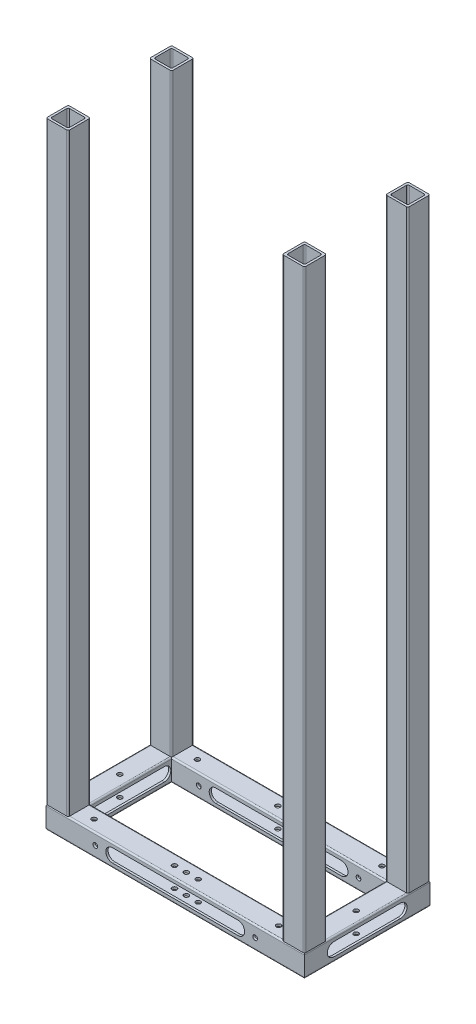
from build123d import *

# Parameters (mm, degrees)
MEMBER_1_DEPTH      = 171.606601718
MEMBER_1_DEPTH_BACK = 11.606601718
MEMBER_1_2_DEPTH    = 93.213203436
MEMBER_1_3_DEPTH    = 183.213203436
MEMBER_1_4_DEPTH    = 93.213203436
MEMBER_2_DEPTH      = 410
MEMBER_2_2_DEPTH    = 410
MEMBER_2_3_DEPTH    = 410
MEMBER_2_4_DEPTH    = 410
CUT_EXTRUDE_START   = -15
SKETCH_13_R         = 1.6
CUT_EXTRUDE_1_DEPTH = 15
CUT_EXTRUDE_START_2 = -85
SKETCH_15_R         = 1.6
CUT_EXTRUDE_2_DEPTH = 85
SKETCH_16_R         = 1.6
CUT_EXTRUDE_3_DEPTH = 15
SKETCH_17_R         = 1.6
CUT_EXTRUDE_4_DEPTH = 15
SKETCH_18_R         = 1.6
CUT_EXTRUDE_5_DEPTH = 15
CUT_EXTRUDE_7_DEPTH = 85
CUT_EXTRUDE_8_DEPTH = 176


with BuildPart() as part:
    # 草图11 → Member 1 (new, two sides)
    with BuildSketch(Plane(origin=(-80, 0, 35), x_dir=(0, 0, -1), z_dir=(1, 0, 0))) as member_1_sk:
        with BuildLine():
            Line((-6.5, 7.5), (6.5, 7.5))
            ThreePointArc((6.5, 7.5), (7.207106781, 7.207106781), (7.5, 6.5))
            Line((7.5, 6.5), (7.5, -6.5))
            ThreePointArc((7.5, -6.5), (7.207106781, -7.207106781), (6.5, -7.5))
            Line((6.5, -7.5), (-6.5, -7.5))
            ThreePointArc((-6.5, -7.5), (-7.207106781, -7.207106781), (-7.5, -6.5))
            Line((-7.5, -6.5), (-7.5, 6.5))
            ThreePointArc((-7.5, 6.5), (-7.207106781, 7.207106781), (-6.5, 7.5))
        make_face()
        with BuildLine():
            Line((-5, 6), (5, 6))
            ThreePointArc((5, 6), (5.707106781, 5.707106781), (6, 5))
            Line((6, 5), (6, -5))
            ThreePointArc((6, -5), (5.707106781, -5.707106781), (5, -6))
            Line((5, -6), (-5, -6))
            ThreePointArc((-5, -6), (-5.707106781, -5.707106781), (-6, -5))
            Line((-6, -5), (-6, 5))
            ThreePointArc((-6, 5), (-5.707106781, 5.707106781), (-5, 6))
        make_face(mode=Mode.SUBTRACT)
    extrude(amount=MEMBER_1_DEPTH)
    extrude(member_1_sk.sketch, amount=-MEMBER_1_DEPTH_BACK)

    # Member 1 mitre 1
    split(bisect_by=Plane(origin=(-80, 0, 35), x_dir=(0, 1, 0), z_dir=(0.707106781, 0, 0.707106781)), keep=Keep.TOP)

    # Member 1 mitre 2
    split(bisect_by=Plane(origin=(80, 0, 35), x_dir=(0, -1, 0), z_dir=(-0.707106781, 0, 0.707106781)), keep=Keep.TOP)


with BuildPart() as body_2:
    # 草图11 on segment 2 (carried to segment 2) → Member 1 2 (new body)
    with BuildSketch(Plane(origin=(80, 0, 46.606601718), x_dir=(-1, 0, 0), z_dir=(0, 0, -1))):
        with BuildLine():
            Line((-6.5, 7.5), (6.5, 7.5))
            ThreePointArc((6.5, 7.5), (7.207106781, 7.207106781), (7.5, 6.5))
            Line((7.5, 6.5), (7.5, -6.5))
            ThreePointArc((7.5, -6.5), (7.207106781, -7.207106781), (6.5, -7.5))
            Line((6.5, -7.5), (-6.5, -7.5))
            ThreePointArc((-6.5, -7.5), (-7.207106781, -7.207106781), (-7.5, -6.5))
            Line((-7.5, -6.5), (-7.5, 6.5))
            ThreePointArc((-7.5, 6.5), (-7.207106781, 7.207106781), (-6.5, 7.5))
        make_face()
        with BuildLine():
            Line((-5, 6), (5, 6))
            ThreePointArc((5, 6), (5.707106781, 5.707106781), (6, 5))
            Line((6, 5), (6, -5))
            ThreePointArc((6, -5), (5.707106781, -5.707106781), (5, -6))
            Line((5, -6), (-5, -6))
            ThreePointArc((-5, -6), (-5.707106781, -5.707106781), (-6, -5))
            Line((-6, -5), (-6, 5))
            ThreePointArc((-6, 5), (-5.707106781, 5.707106781), (-5, 6))
        make_face(mode=Mode.SUBTRACT)
    extrude(amount=MEMBER_1_2_DEPTH)

    # Member 1 2 mitre 1
    split(bisect_by=Plane(origin=(80, 0, -35), x_dir=(0, 1, 0), z_dir=(0.707106781, 0, 0.707106781)), keep=Keep.TOP)

    # Member 1 2 mitre 2
    split(bisect_by=Plane(origin=(80, 0, 35), x_dir=(0, 1, 0), z_dir=(0.707106781, 0, -0.707106781)), keep=Keep.TOP)


with BuildPart() as body_3:
    # 草图11 on segment 3 (carried to segment 3) → Member 1 3 (new body)
    with BuildSketch(Plane(origin=(91.606601718, 0, -35), x_dir=(0, 0, 1), z_dir=(-1, 0, 0))):
        with BuildLine():
            Line((-6.5, 7.5), (6.5, 7.5))
            ThreePointArc((6.5, 7.5), (7.207106781, 7.207106781), (7.5, 6.5))
            Line((7.5, 6.5), (7.5, -6.5))
            ThreePointArc((7.5, -6.5), (7.207106781, -7.207106781), (6.5, -7.5))
            Line((6.5, -7.5), (-6.5, -7.5))
            ThreePointArc((-6.5, -7.5), (-7.207106781, -7.207106781), (-7.5, -6.5))
            Line((-7.5, -6.5), (-7.5, 6.5))
            ThreePointArc((-7.5, 6.5), (-7.207106781, 7.207106781), (-6.5, 7.5))
        make_face()
        with BuildLine():
            Line((-5, 6), (5, 6))
            ThreePointArc((5, 6), (5.707106781, 5.707106781), (6, 5))
            Line((6, 5), (6, -5))
            ThreePointArc((6, -5), (5.707106781, -5.707106781), (5, -6))
            Line((5, -6), (-5, -6))
            ThreePointArc((-5, -6), (-5.707106781, -5.707106781), (-6, -5))
            Line((-6, -5), (-6, 5))
            ThreePointArc((-6, 5), (-5.707106781, 5.707106781), (-5, 6))
        make_face(mode=Mode.SUBTRACT)
    extrude(amount=MEMBER_1_3_DEPTH)

    # Member 1 3 mitre 1
    split(bisect_by=Plane(origin=(-80, 0, -35), x_dir=(0, 1, 0), z_dir=(0.707106781, 0, -0.707106781)), keep=Keep.TOP)

    # Member 1 3 mitre 2
    split(bisect_by=Plane(origin=(80, 0, -35), x_dir=(0, -1, 0), z_dir=(-0.707106781, 0, -0.707106781)), keep=Keep.TOP)


with BuildPart() as body_4:
    # 草图11 on segment 4 (carried to segment 4) → Member 1 4 (new body)
    with BuildSketch(Plane(origin=(-80, 0, -46.606601718), x_dir=(1, 0, 0), z_dir=(0, 0, 1))):
        with BuildLine():
            Line((-6.5, 7.5), (6.5, 7.5))
            ThreePointArc((6.5, 7.5), (7.207106781, 7.207106781), (7.5, 6.5))
            Line((7.5, 6.5), (7.5, -6.5))
            ThreePointArc((7.5, -6.5), (7.207106781, -7.207106781), (6.5, -7.5))
            Line((6.5, -7.5), (-6.5, -7.5))
            ThreePointArc((-6.5, -7.5), (-7.207106781, -7.207106781), (-7.5, -6.5))
            Line((-7.5, -6.5), (-7.5, 6.5))
            ThreePointArc((-7.5, 6.5), (-7.207106781, 7.207106781), (-6.5, 7.5))
        make_face()
        with BuildLine():
            Line((-5, 6), (5, 6))
            ThreePointArc((5, 6), (5.707106781, 5.707106781), (6, 5))
            Line((6, 5), (6, -5))
            ThreePointArc((6, -5), (5.707106781, -5.707106781), (5, -6))
            Line((5, -6), (-5, -6))
            ThreePointArc((-5, -6), (-5.707106781, -5.707106781), (-6, -5))
            Line((-6, -5), (-6, 5))
            ThreePointArc((-6, 5), (-5.707106781, 5.707106781), (-5, 6))
        make_face(mode=Mode.SUBTRACT)
    extrude(amount=MEMBER_1_4_DEPTH)

    # Member 1 4 mitre 1
    split(bisect_by=Plane(origin=(-80, 0, -35), x_dir=(0, -1, 0), z_dir=(-0.707106781, 0, 0.707106781)), keep=Keep.TOP)

    # Member 1 4 mitre 2
    split(bisect_by=Plane(origin=(-80, 0, 35), x_dir=(0, -1, 0), z_dir=(-0.707106781, 0, -0.707106781)), keep=Keep.TOP)


with BuildPart() as body_5:
    # 草图12 → Member 2 (new body)
    with BuildSketch(Plane(origin=(-80, 0, 35), x_dir=(1, 0, 0), z_dir=(0, 1, 0))):
        with BuildLine():
            Line((-6.5, 7.5), (6.5, 7.5))
            ThreePointArc((6.5, 7.5), (7.207106781, 7.207106781), (7.5, 6.5))
            Line((7.5, 6.5), (7.5, -6.5))
            ThreePointArc((7.5, -6.5), (7.207106781, -7.207106781), (6.5, -7.5))
            Line((6.5, -7.5), (-6.5, -7.5))
            ThreePointArc((-6.5, -7.5), (-7.207106781, -7.207106781), (-7.5, -6.5))
            Line((-7.5, -6.5), (-7.5, 6.5))
            ThreePointArc((-7.5, 6.5), (-7.207106781, 7.207106781), (-6.5, 7.5))
        make_face()
        with BuildLine():
            Line((-5, 6), (5, 6))
            ThreePointArc((5, 6), (5.707106781, 5.707106781), (6, 5))
            Line((6, 5), (6, -5))
            ThreePointArc((6, -5), (5.707106781, -5.707106781), (5, -6))
            Line((5, -6), (-5, -6))
            ThreePointArc((-5, -6), (-5.707106781, -5.707106781), (-6, -5))
            Line((-6, -5), (-6, 5))
            ThreePointArc((-6, 5), (-5.707106781, 5.707106781), (-5, 6))
        make_face(mode=Mode.SUBTRACT)
    extrude(amount=MEMBER_2_DEPTH)

    # Weld Trim 1 5
    split(bisect_by=Plane(origin=(0, 7.5, 35.176724987), x_dir=(-1, 0, 0), z_dir=(0, 1, 0)), keep=Keep.TOP)


with BuildPart() as body_6:
    # 草图12 on segment 2 (carried to segment 2) → Member 2 2 (new body)
    with BuildSketch(Plane(origin=(-80, 0, -35), x_dir=(1, 0, 0), z_dir=(0, 1, 0))):
        with BuildLine():
            Line((-6.5, 7.5), (6.5, 7.5))
            ThreePointArc((6.5, 7.5), (7.207106781, 7.207106781), (7.5, 6.5))
            Line((7.5, 6.5), (7.5, -6.5))
            ThreePointArc((7.5, -6.5), (7.207106781, -7.207106781), (6.5, -7.5))
            Line((6.5, -7.5), (-6.5, -7.5))
            ThreePointArc((-6.5, -7.5), (-7.207106781, -7.207106781), (-7.5, -6.5))
            Line((-7.5, -6.5), (-7.5, 6.5))
            ThreePointArc((-7.5, 6.5), (-7.207106781, 7.207106781), (-6.5, 7.5))
        make_face()
        with BuildLine():
            Line((-5, 6), (5, 6))
            ThreePointArc((5, 6), (5.707106781, 5.707106781), (6, 5))
            Line((6, 5), (6, -5))
            ThreePointArc((6, -5), (5.707106781, -5.707106781), (5, -6))
            Line((5, -6), (-5, -6))
            ThreePointArc((-5, -6), (-5.707106781, -5.707106781), (-6, -5))
            Line((-6, -5), (-6, 5))
            ThreePointArc((-6, 5), (-5.707106781, 5.707106781), (-5, 6))
        make_face(mode=Mode.SUBTRACT)
    extrude(amount=MEMBER_2_2_DEPTH)

    # Weld Trim 1 5
    split(bisect_by=Plane(origin=(0, 7.5, 35.176724987), x_dir=(-1, 0, 0), z_dir=(0, 1, 0)), keep=Keep.TOP)


with BuildPart() as body_7:
    # 草图12 on segment 3 (carried to segment 3) → Member 2 3 (new body)
    with BuildSketch(Plane(origin=(80, 0, -35), x_dir=(1, 0, 0), z_dir=(0, 1, 0))):
        with BuildLine():
            Line((-6.5, 7.5), (6.5, 7.5))
            ThreePointArc((6.5, 7.5), (7.207106781, 7.207106781), (7.5, 6.5))
            Line((7.5, 6.5), (7.5, -6.5))
            ThreePointArc((7.5, -6.5), (7.207106781, -7.207106781), (6.5, -7.5))
            Line((6.5, -7.5), (-6.5, -7.5))
            ThreePointArc((-6.5, -7.5), (-7.207106781, -7.207106781), (-7.5, -6.5))
            Line((-7.5, -6.5), (-7.5, 6.5))
            ThreePointArc((-7.5, 6.5), (-7.207106781, 7.207106781), (-6.5, 7.5))
        make_face()
        with BuildLine():
            Line((-5, 6), (5, 6))
            ThreePointArc((5, 6), (5.707106781, 5.707106781), (6, 5))
            Line((6, 5), (6, -5))
            ThreePointArc((6, -5), (5.707106781, -5.707106781), (5, -6))
            Line((5, -6), (-5, -6))
            ThreePointArc((-5, -6), (-5.707106781, -5.707106781), (-6, -5))
            Line((-6, -5), (-6, 5))
            ThreePointArc((-6, 5), (-5.707106781, 5.707106781), (-5, 6))
        make_face(mode=Mode.SUBTRACT)
    extrude(amount=MEMBER_2_3_DEPTH)

    # Weld Trim 1 5
    split(bisect_by=Plane(origin=(0, 7.5, 35.176724987), x_dir=(-1, 0, 0), z_dir=(0, 1, 0)), keep=Keep.TOP)


with BuildPart() as body_8:
    # 草图12 on segment 4 (carried to segment 4) → Member 2 4 (new body)
    with BuildSketch(Plane(origin=(80, 0, 35), x_dir=(1, 0, 0), z_dir=(0, 1, 0))):
        with BuildLine():
            Line((-6.5, 7.5), (6.5, 7.5))
            ThreePointArc((6.5, 7.5), (7.207106781, 7.207106781), (7.5, 6.5))
            Line((7.5, 6.5), (7.5, -6.5))
            ThreePointArc((7.5, -6.5), (7.207106781, -7.207106781), (6.5, -7.5))
            Line((6.5, -7.5), (-6.5, -7.5))
            ThreePointArc((-6.5, -7.5), (-7.207106781, -7.207106781), (-7.5, -6.5))
            Line((-7.5, -6.5), (-7.5, 6.5))
            ThreePointArc((-7.5, 6.5), (-7.207106781, 7.207106781), (-6.5, 7.5))
        make_face()
        with BuildLine():
            Line((-5, 6), (5, 6))
            ThreePointArc((5, 6), (5.707106781, 5.707106781), (6, 5))
            Line((6, 5), (6, -5))
            ThreePointArc((6, -5), (5.707106781, -5.707106781), (5, -6))
            Line((5, -6), (-5, -6))
            ThreePointArc((-5, -6), (-5.707106781, -5.707106781), (-6, -5))
            Line((-6, -5), (-6, 5))
            ThreePointArc((-6, 5), (-5.707106781, 5.707106781), (-5, 6))
        make_face(mode=Mode.SUBTRACT)
    extrude(amount=MEMBER_2_4_DEPTH)

    # Weld Trim 1 5
    split(bisect_by=Plane(origin=(0, 7.5, 35.176724987), x_dir=(-1, 0, 0), z_dir=(0, 1, 0)), keep=Keep.TOP)


with BuildPart() as cut_extrude_1_tool:
    # 草图13 → 切除-拉伸1 (new body)
    with BuildSketch(Plane(origin=(0, 7.5, 0), x_dir=(1, 0, 0), z_dir=(0, 1, 0)).offset(CUT_EXTRUDE_START)):
        with Locations(Location((0, -35, 0), (0, 0, 270))):
            Circle(SKETCH_13_R)
        with Locations(Location((0, 35, 0), (0, 0, 90))):
            Circle(SKETCH_13_R)
    extrude(amount=CUT_EXTRUDE_1_DEPTH)


with BuildPart() as part_1:
    add(part.part)

    # 切除-拉伸1: cut by cut_extrude_1_tool
    add(cut_extrude_1_tool.part, mode=Mode.SUBTRACT)


with BuildPart() as body_3_1:
    add(body_3.part)

    # 切除-拉伸1: cut by cut_extrude_1_tool
    add(cut_extrude_1_tool.part, mode=Mode.SUBTRACT)


with BuildPart() as cut_extrude_2_tool:
    # 草图15 → 切除-拉伸2 (new body)
    with BuildSketch(Plane(origin=(0, 0, -42.5), x_dir=(-1, 0, 0), z_dir=(0, 0, -1)).offset(CUT_EXTRUDE_START_2)):
        with Locations((-54.11, 0)):
            Circle(SKETCH_15_R)
        with Locations((54.11, 0)):
            Circle(SKETCH_15_R)
    extrude(amount=CUT_EXTRUDE_2_DEPTH)


with BuildPart() as part_2:
    add(part_1.part)

    # 切除-拉伸2: cut by cut_extrude_2_tool
    add(cut_extrude_2_tool.part, mode=Mode.SUBTRACT)


with BuildPart() as body_3_2:
    add(body_3_1.part)

    # 切除-拉伸2: cut by cut_extrude_2_tool
    add(cut_extrude_2_tool.part, mode=Mode.SUBTRACT)


with BuildPart() as cut_extrude_3_tool:
    # 草图16 → 切除-拉伸3 (new body)
    with BuildSketch(Plane(origin=(0, 7.5, 0), x_dir=(1, 0, 0), z_dir=(0, 1, 0)).offset(CUT_EXTRUDE_START)):
        with Locations(Location((80, 0, 0), (0, 0, 270))):
            Circle(SKETCH_16_R)
        with Locations(Location((-80, 0, 0), (0, 0, 270))):
            Circle(SKETCH_16_R)
    extrude(amount=CUT_EXTRUDE_3_DEPTH)


with BuildPart() as body_2_1:
    add(body_2.part)

    # 切除-拉伸3: cut by cut_extrude_3_tool
    add(cut_extrude_3_tool.part, mode=Mode.SUBTRACT)


with BuildPart() as body_4_1:
    add(body_4.part)

    # 切除-拉伸3: cut by cut_extrude_3_tool
    add(cut_extrude_3_tool.part, mode=Mode.SUBTRACT)


with BuildPart() as cut_extrude_4_tool:
    # 草图17 → 切除-拉伸4 (new body)
    with BuildSketch(Plane(origin=(0, 7.5, 0), x_dir=(1, 0, 0), z_dir=(0, 1, 0)).offset(CUT_EXTRUDE_START)):
        with Locations(Location((8, 35, 0), (0, 0, 180))):
            Circle(SKETCH_17_R)
        with Locations(Location((-8, 35, 0), (0, 0, 90))):
            Circle(SKETCH_17_R)
        with Locations(Location((-8, -35, 0), (0, 0, 180))):
            Circle(SKETCH_17_R)
        with Locations(Location((8, -35, 0), (0, 0, 90))):
            Circle(SKETCH_17_R)
    extrude(amount=CUT_EXTRUDE_4_DEPTH)


with BuildPart() as part_3:
    add(part_2.part)

    # 切除-拉伸4: cut by cut_extrude_4_tool
    add(cut_extrude_4_tool.part, mode=Mode.SUBTRACT)


with BuildPart() as body_3_3:
    add(body_3_2.part)

    # 切除-拉伸4: cut by cut_extrude_4_tool
    add(cut_extrude_4_tool.part, mode=Mode.SUBTRACT)


with BuildPart() as cut_extrude_5_tool:
    # 草图18 → 切除-拉伸5 (new body)
    with BuildSketch(Plane(origin=(0, 7.5, 0), x_dir=(1, 0, 0), z_dir=(0, 1, 0)).offset(CUT_EXTRUDE_START)):
        with Locations(Location((-62.5, -35, 0), (0, 0, 270))):
            Circle(SKETCH_18_R)
        with Locations(Location((62.5, -35, 0), (0, 0, 270))):
            Circle(SKETCH_18_R)
        with Locations(Location((62.5, 35, 0), (0, 0, 270))):
            Circle(SKETCH_18_R)
        with Locations(Location((-62.5, 35, 0), (0, 0, 270))):
            Circle(SKETCH_18_R)
    extrude(amount=CUT_EXTRUDE_5_DEPTH)


with BuildPart() as part_4:
    add(part_3.part)

    # 切除-拉伸5: cut by cut_extrude_5_tool
    add(cut_extrude_5_tool.part, mode=Mode.SUBTRACT)


with BuildPart() as body_3_4:
    add(body_3_3.part)

    # 切除-拉伸5: cut by cut_extrude_5_tool
    add(cut_extrude_5_tool.part, mode=Mode.SUBTRACT)


with BuildPart() as cut_extrude_7_tool:
    # 草图22 → 切除-拉伸7 (new body)
    with BuildSketch(Plane(origin=(0, 0, -42.5), x_dir=(-1, 0, 0), z_dir=(0, 0, -1))):
        with BuildLine():
            Line((-42.5, 4.5), (42.5, 4.5))
            ThreePointArc((42.5, 4.5), (47, 0), (42.5, -4.5))
            Line((42.5, -4.5), (-42.5, -4.5))
            ThreePointArc((-42.5, -4.5), (-47, 0), (-42.5, 4.5))
        make_face()
    extrude(amount=-CUT_EXTRUDE_7_DEPTH)


with BuildPart() as part_5:
    add(part_4.part)

    # 切除-拉伸7: cut by cut_extrude_7_tool
    add(cut_extrude_7_tool.part, mode=Mode.SUBTRACT)


with BuildPart() as body_3_5:
    add(body_3_4.part)

    # 切除-拉伸7: cut by cut_extrude_7_tool
    add(cut_extrude_7_tool.part, mode=Mode.SUBTRACT)


with BuildPart() as cut_extrude_8_tool:
    # 草图23 → 切除-拉伸8 (new body)
    with BuildSketch(Plane(origin=(87.5, 0, 0), x_dir=(0, 0, -1), z_dir=(1, 0, 0))):
        with BuildLine():
            Line((-22.5, 4.5), (22.5, 4.5))
            ThreePointArc((22.5, 4.5), (27, 0), (22.5, -4.5))
            Line((22.5, -4.5), (-22.5, -4.5))
            ThreePointArc((-22.5, -4.5), (-27, 0), (-22.5, 4.5))
        make_face()
    extrude(amount=-CUT_EXTRUDE_8_DEPTH)


with BuildPart() as body_2_2:
    add(body_2_1.part)

    # 切除-拉伸8: cut by cut_extrude_8_tool
    add(cut_extrude_8_tool.part, mode=Mode.SUBTRACT)


with BuildPart() as body_4_2:
    add(body_4_1.part)

    # 切除-拉伸8: cut by cut_extrude_8_tool
    add(cut_extrude_8_tool.part, mode=Mode.SUBTRACT)


solid = Compound([body_5.part, body_6.part, body_7.part, body_8.part, part_5.part, body_3_5.part, body_2_2.part, body_4_2.part])
